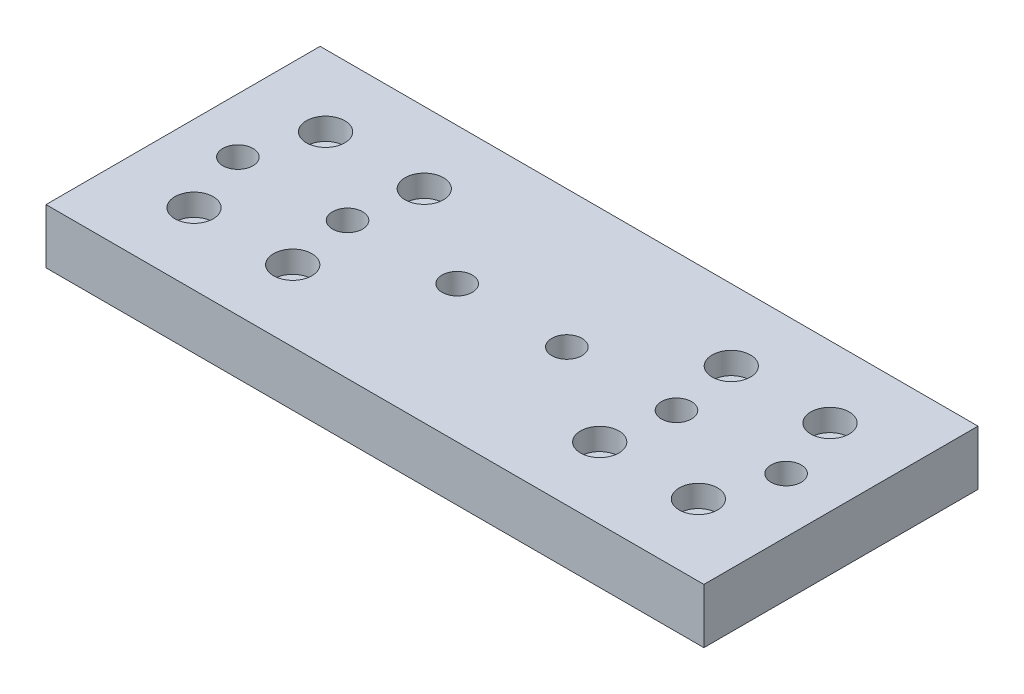
from build123d import *

# Parameters (mm, degrees)
SKETCH1_W                                            = 120
SKETCH1_H                                            = 50
MAIN_DEPTH                                           = 10
SKETCH2_R                                            = 1.5
LINEAR_BEARING_MOUNT_DEPTH                           = 11
SKETCH5_R                                            = 3.5
LINEAR_BEARING_COUNTERSINK_DEPTH                     = 4
SKETCH6_R                                            = 2.5
CUT_EXTRUDE1_DEPTH                                   = 11
CSK_FOR_M5_SOCKET_COUNTERSUNK_HEAD_SCREW_D           = 5.5
CSK_FOR_M5_SOCKET_COUNTERSUNK_HEAD_SCREW_DEPTH       = 10
CSK_FOR_M5_SOCKET_COUNTERSUNK_HEAD_SCREW_CSINK_D     = 11.47
CSK_FOR_M5_SOCKET_COUNTERSUNK_HEAD_SCREW_CSINK_ANGLE = 90
CSK_FOR_M5_SOCKET_COUNTERSUNK_HEAD_SCREW_TIP         = 1.652366702


with BuildPart() as part:
    # Sketch1 → main (new body)
    with BuildSketch(Plane(origin=(0, 0, 0), x_dir=(1, 0, 0), z_dir=(0, 1, 0))):
        Rectangle(SKETCH1_W, SKETCH1_H)
    extrude(amount=MAIN_DEPTH)

    # Sketch2 → linear_bearing_mount (cut, through all)
    with BuildSketch(Plane(origin=(0, 10, 0), x_dir=(1, 0, 0), z_dir=(0, 1, 0))):
        with Locations((-28, -12)):
            Circle(SKETCH2_R)
        with Locations((-46, -12)):
            Circle(SKETCH2_R)
        with Locations((28, -12)):
            Circle(SKETCH2_R)
        with Locations((46, -12)):
            Circle(SKETCH2_R)
        with Locations((46, 12)):
            Circle(SKETCH2_R)
        with Locations((28, 12)):
            Circle(SKETCH2_R)
        with Locations((-46, 12)):
            Circle(SKETCH2_R)
        with Locations((-28, 12)):
            Circle(SKETCH2_R)
    extrude(amount=-LINEAR_BEARING_MOUNT_DEPTH, mode=Mode.SUBTRACT)

    # Sketch5 → linear_bearing_countersink (cut)
    with BuildSketch(Plane(origin=(0, 10, 0), x_dir=(1, 0, 0), z_dir=(0, 1, 0))):
        with Locations((-46, 12)):
            Circle(SKETCH5_R)
        with Locations((-28, 12)):
            Circle(SKETCH5_R)
        with Locations((-28, -12)):
            Circle(SKETCH5_R)
        with Locations((-46, -12)):
            Circle(SKETCH5_R)
        with Locations((46, -12)):
            Circle(SKETCH5_R)
        with Locations((28, -12)):
            Circle(SKETCH5_R)
        with Locations((28, 12)):
            Circle(SKETCH5_R)
        with Locations((46, 12)):
            Circle(SKETCH5_R)
    extrude(amount=-LINEAR_BEARING_COUNTERSINK_DEPTH, mode=Mode.SUBTRACT)

    # Sketch6 → Cut-Extrude1 (cut, through all)
    with BuildSketch(Plane.XZ):
        with Locations((-50, 0)):
            Circle(SKETCH6_R)
        with Locations((-30, 0)):
            Circle(SKETCH6_R)
        with Locations((-10, 0)):
            Circle(SKETCH6_R)
        with Locations((10, 0)):
            Circle(SKETCH6_R)
        with Locations((30, 0)):
            Circle(SKETCH6_R)
        with Locations((50, 0)):
            Circle(SKETCH6_R)
    extrude(amount=-CUT_EXTRUDE1_DEPTH, mode=Mode.SUBTRACT)

    # CSK for M5 socket countersunk head screw1
    with Locations(Plane(origin=(0, 0, 0), x_dir=(-1, 0, 0), z_dir=(0, -1, 0))):
        with Locations((-50, 0), (-30, 0), (-10, 0), (10, 0), (30, 0), (50, 0)):
            CounterSinkHole(CSK_FOR_M5_SOCKET_COUNTERSUNK_HEAD_SCREW_D / 2, CSK_FOR_M5_SOCKET_COUNTERSUNK_HEAD_SCREW_CSINK_D / 2, depth=CSK_FOR_M5_SOCKET_COUNTERSUNK_HEAD_SCREW_DEPTH, counter_sink_angle=CSK_FOR_M5_SOCKET_COUNTERSUNK_HEAD_SCREW_CSINK_ANGLE)
            with Locations((0, 0, -(CSK_FOR_M5_SOCKET_COUNTERSUNK_HEAD_SCREW_DEPTH + CSK_FOR_M5_SOCKET_COUNTERSUNK_HEAD_SCREW_TIP / 2))):  # 118° drill point
                Cone(0, CSK_FOR_M5_SOCKET_COUNTERSUNK_HEAD_SCREW_D / 2, CSK_FOR_M5_SOCKET_COUNTERSUNK_HEAD_SCREW_TIP, mode=Mode.SUBTRACT)


solid = part.part
